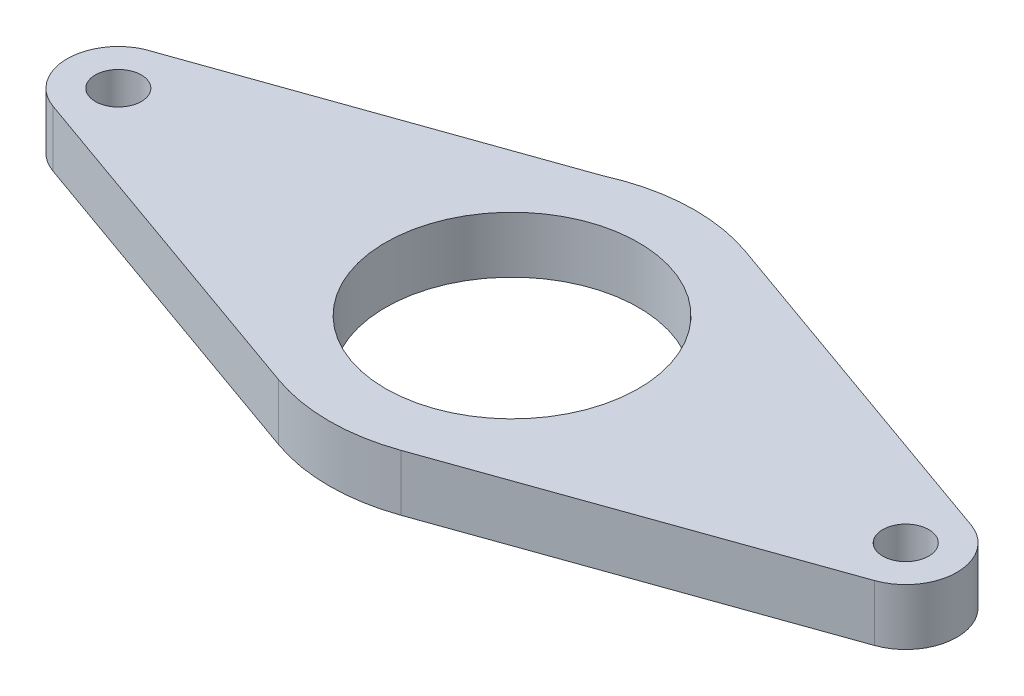
from build123d import *

# Parameters (mm, degrees)
SKETCH1_R           = 14.2875
SKETCH1_R_2         = 2.6
BOSS_EXTRUDE2_DEPTH = 6.35


with BuildPart() as part:
    # Sketch1 → Boss-Extrude2 (new body)
    with BuildSketch(Plane(origin=(0, 0, 0), x_dir=(1, 0, 0), z_dir=(0, 1, 0))):
        with BuildLine():
            Line((46.380954724, 5.442613237), (6.900446429, 19.449684968))
            ThreePointArc((6.900446429, 19.449684968), (-0.8307112, 20.620774116), (-8.442613636, 18.831587327))
            Line((-8.442613636, 18.831587327), (-46.8125, 5.269650724))
            ThreePointArc((-46.8125, 5.269650724), (-50.220319589, -0.232458252), (-46.380954724, -5.442613237))
            Line((-46.380954724, -5.442613237), (-6.900446429, -19.449684968))
            ThreePointArc((-6.900446429, -19.449684968), (0, -20.6375), (6.900446429, -19.449684968))
            Line((6.900446429, -19.449684968), (46.380954724, -5.442613237))
            ThreePointArc((46.380954724, -5.442613237), (50.225, 0), (46.380954724, 5.442613237))
        make_face()
        Circle(SKETCH1_R, mode=Mode.SUBTRACT)
        with Locations((44.45, 0)):
            Circle(SKETCH1_R_2, mode=Mode.SUBTRACT)
        with Locations((-44.45, 0)):
            Circle(SKETCH1_R_2, mode=Mode.SUBTRACT)
    extrude(amount=BOSS_EXTRUDE2_DEPTH)


solid = part.part
